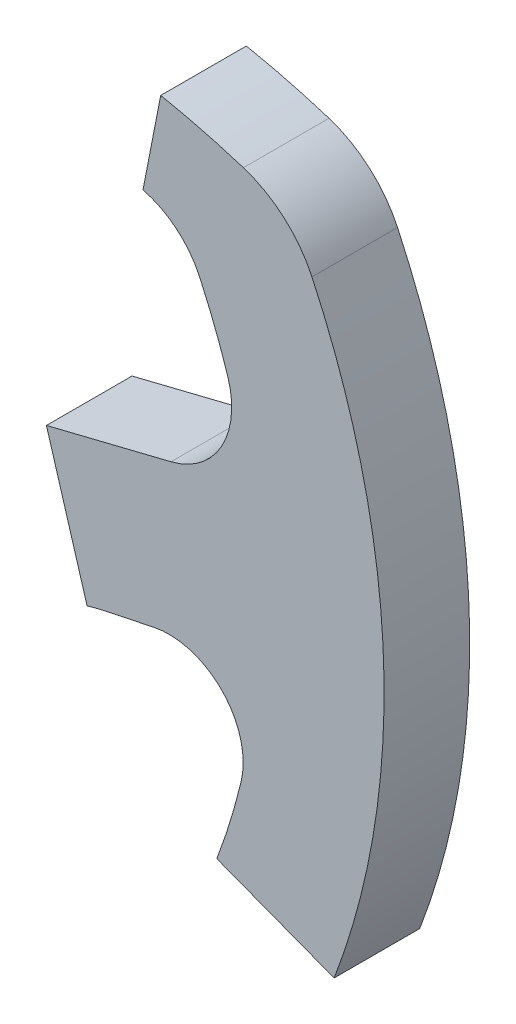
from build123d import *

# Parameters (mm, degrees)
DODANIE_WYCI_GNI_CIE1_DEPTH = 15


with BuildPart() as part:
    # Szkic2 → Dodanie-wyciągnięcie1 (new body)
    with BuildSketch(Plane(origin=(0, 0, 0), x_dir=(-1, 0, 0), z_dir=(0, 0, -1))):
        with BuildLine():
            Line((-74.826032056, 11.014530402), (-81.951422725, -12.818572719))
            ThreePointArc((-81.951422725, -12.818572719), (-83.679858685, -12.341119841), (-85.426816489, -11.936656557))
            Line((-85.426816489, -11.936656557), (-93.639920436, -10.215979742))
            ThreePointArc((-93.639920436, -10.215979742), (-105.622705702, -13.873790687), (-108.951787413, -25.952033051))
            ThreePointArc((-108.951787413, -25.952033051), (-107.042286981, -32.953737236), (-104.683334782, -39.817074466))
            Line((-104.683334782, -39.817074466), (-125.246132685, -47.638285521))
            ThreePointArc((-125.246132685, -47.638285521), (-133.907193125, 4.986344284), (-121.356345693, 56.821099602))
            ThreePointArc((-121.356345693, 56.821099602), (-116.45353268, 63.356793916), (-109.346193532, 67.386509274))
            ThreePointArc((-109.346193532, 67.386509274), (-102.153493063, 69.460884834), (-94.851646537, 71.110433658))
            Line((-94.851646537, 71.110433658), (-91.74794023, 55.218917354))
            ThreePointArc((-91.74794023, 55.218917354), (-97.643827413, 52.217038431), (-101.674756414, 46.970670723))
            ThreePointArc((-101.674756414, 46.970670723), (-104.340687454, 40.706522101), (-106.621107385, 34.291973698))
            ThreePointArc((-106.621107385, 34.291973698), (-105.521825108, 23.188783802), (-96.655711946, 16.415211274))
            Line((-96.655711946, 16.415211274), (-74.826032056, 11.014530402))
        make_face()
    extrude(amount=DODANIE_WYCI_GNI_CIE1_DEPTH)


solid = part.part
